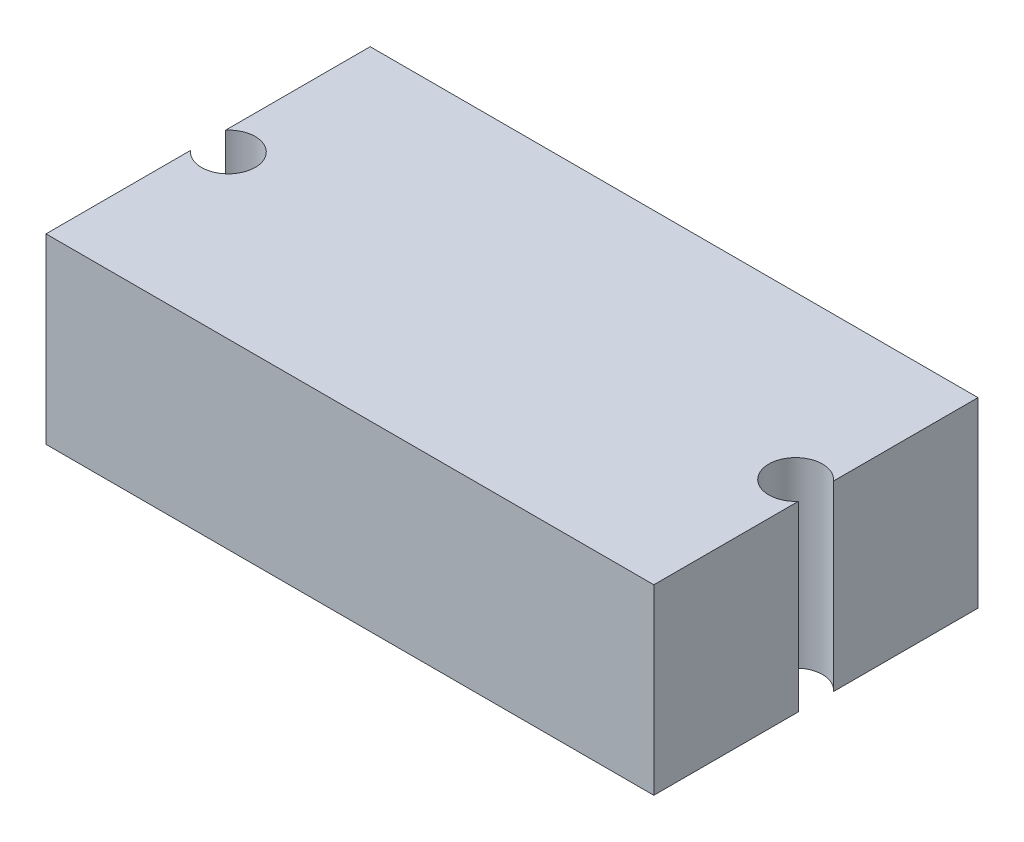
from build123d import *

# Parameters (mm, degrees)
SKETCH_1_W          = 60
SKETCH_1_H          = 32
EXTRUDE_1_DEPTH     = 18
SKETCH_2_R          = 2.65
CUT_EXTRUDE_1_DEPTH = 19


with BuildPart() as part:
    # 草图1 → 凸台-拉伸1 (new body)
    with BuildSketch(Plane(origin=(0, 0, 0), x_dir=(1, 0, 0), z_dir=(0, 1, 0))):
        Rectangle(SKETCH_1_W, SKETCH_1_H)
    extrude(amount=EXTRUDE_1_DEPTH)

    # 草图2 → 切除-拉伸1 (cut, through all)
    with BuildSketch(Plane(origin=(0, 18, 0), x_dir=(1, 0, 0), z_dir=(0, 1, 0))):
        with Locations((-28, 0)):
            Circle(SKETCH_2_R)
        with Locations((28, 0)):
            Circle(SKETCH_2_R)
    extrude(amount=-CUT_EXTRUDE_1_DEPTH, mode=Mode.SUBTRACT)


solid = part.part
